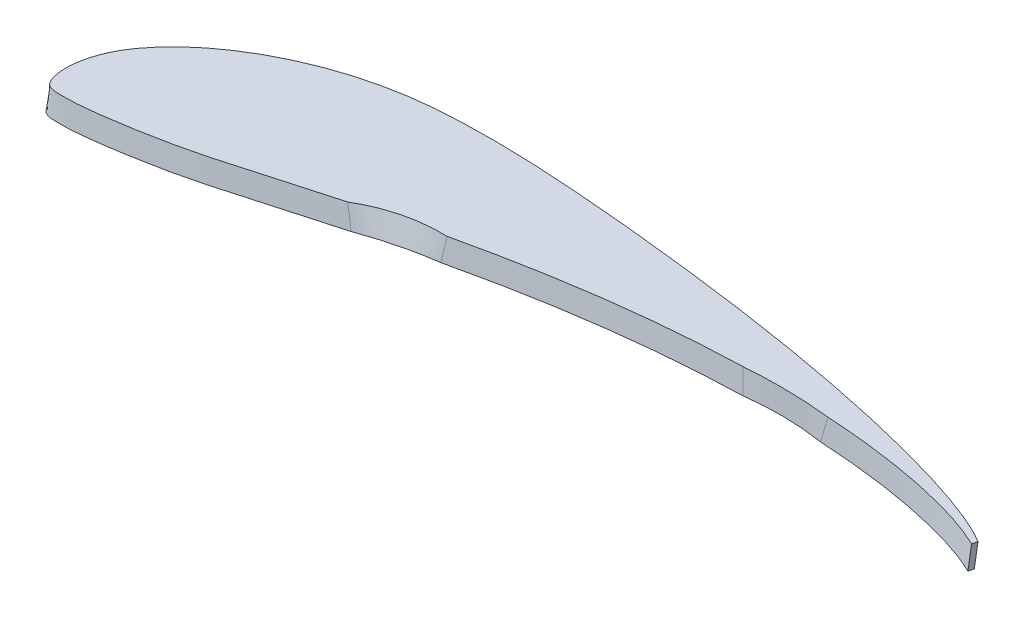
from build123d import *


with BuildPart() as part:
    # Szkic1 → Wyciągnięcie po profilach1 section 0
    with BuildSketch(Plane(origin=(0, 250.36091718, 48.665232477), x_dir=(1, 0, 0), z_dir=(0, -0.981627183, -0.190808995))):
        with BuildLine():
            Line((-230.718181465, 186.71807225), (-231.645319449, 188.691942525))
            add(Edge.make_bspline(
                [(-231.645319449, 188.691942525), (-233.174644141, 187.999953464), (-234.721783332, 187.364140241), (-237.841249221, 186.171939505), (-239.414020678, 185.616954481), (-244.164400083, 184.053112564), (-247.374501337, 183.146719317), (-253.851623397, 181.51342164), (-257.119855918, 180.780316602), (-263.657686797, 179.453922888), (-266.932791453, 178.860184209), (-276.773612098, 177.252991106), (-283.354734665, 176.412436258), (-296.548078516, 175.080330415), (-303.160298205, 174.588761507), (-309.785788347, 174.246119623)],
                knots=[0, 0, 0, 0, 0.0625, 0.0625, 0.125, 0.125, 0.25, 0.25, 0.375, 0.375, 0.5, 0.5, 0.75, 0.75, 1, 1, 1, 1], degree=3))
            add(Edge.make_bspline(
                [(-348.183016714, 173.781671183), (-328.964171571, 172.456994761), (-309.785788347, 174.246119623)],
                knots=[0, 0, 0, 1, 1, 1], degree=2))
            add(Edge.make_bspline(
                [(-348.183016714, 173.781671183), (-358.151666656, 174.022025786), (-368.096286676, 174.522537173), (-387.94418485, 175.971142244), (-397.847591779, 176.917841756), (-417.618208057, 179.203129122), (-427.484934044, 180.546950038), (-442.260684852, 182.826175434), (-447.183290441, 183.629033837), (-457.009652818, 185.314266402), (-461.914365461, 186.197158818), (-466.811292159, 187.117080937)],
                knots=[0, 0, 0, 0, 0.25, 0.25, 0.5, 0.5, 0.75, 0.75, 0.875, 0.875, 1, 1, 1, 1], degree=3))
            add(Edge.make_bspline(
                [(-503.67525068, 194.699844137), (-486.113087933, 186.628450015), (-466.811292159, 187.117080937)],
                knots=[0, 0, 0, 1, 1, 1], degree=2))
            add(Edge.make_bspline(
                [(-503.67525068, 194.699844137), (-514.886156137, 197.183158341), (-526.069069208, 199.799603445), (-542.843173548, 203.725532692), (-548.433789911, 205.045195718), (-556.847390253, 206.862217693), (-559.656198502, 207.441328721), (-565.285707455, 208.525652892), (-568.106893587, 209.027849652), (-573.758546812, 209.974572715), (-576.588548469, 210.421991156), (-582.255411466, 211.274203028), (-585.092466698, 211.677791635), (-590.775811551, 212.427587781), (-593.622461186, 212.771558242), (-597.902598645, 213.224362574), (-599.33093878, 213.36518339), (-602.190977957, 213.625953291), (-603.621807395, 213.74850469), (-605.769052097, 213.890532369), (-606.485034549, 213.930761383), (-607.917647629, 213.991533363), (-608.634307809, 214.011178807), (-610.068244724, 214.031744007), (-610.785502514, 214.03323918), (-612.220370634, 214.025522336), (-612.937904151, 214.018643253), (-614.373446848, 213.990438557), (-615.094405741, 213.959551393), (-616.154316733, 213.800587864), (-616.504425777, 213.729005846), (-617.19627763, 213.537146432), (-617.539907955, 213.417073554), (-618.025928813, 213.187044681), (-618.183588752, 213.101834107), (-618.487632655, 212.909275387), (-618.635214003, 212.800703818), (-618.905216661, 212.56311753), (-619.028373994, 212.433641543), (-619.248292015, 212.150880775), (-619.346463926, 211.996467784), (-619.602643649, 211.519652342), (-619.725174636, 211.184978082), (-619.922621807, 210.499055279), (-619.997357698, 210.146675653), (-620.122117308, 209.439404469), (-620.169952886, 209.083937157), (-620.236946265, 208.369390812), (-620.256057026, 208.009403538), (-620.272323599, 206.93673215), (-620.228983229, 206.228087719), (-620.060745622, 204.820536998), (-619.93589689, 204.121624917), (-619.624483911, 202.731169778), (-619.437495298, 202.038892606), (-618.800725774, 200.000887185), (-618.274140545, 198.683280498), (-617.06173932, 196.112125571), (-616.37402886, 194.854996442), (-614.892048313, 192.440246872), (-614.092796263, 191.278019838), (-612.383886198, 189.039120678), (-611.475247542, 187.961658639), (-610.045682759, 186.397079988), (-609.558049109, 185.884164636), (-608.562812036, 184.87380875), (-608.054261942, 184.375495234), (-606.510608451, 182.909046548), (-605.457949932, 181.968180201), (-602.246891056, 179.228432719), (-600.032107811, 177.517553058), (-595.480994707, 174.285501661), (-593.145169014, 172.763543035), (-588.374611336, 169.873997071), (-585.940036539, 168.506164399), (-580.983288597, 165.907221095), (-578.460054833, 164.67776586), (-574.613641656, 162.92966878), (-573.321179813, 162.362813896), (-570.72874085, 161.263307356), (-569.427344918, 160.729821284), (-565.508102562, 159.176672617), (-562.875139683, 158.204514072), (-557.57061981, 156.381480503), (-554.89911711, 155.530434856), (-549.519642901, 153.942948231), (-546.811580447, 153.206793044), (-542.719703975, 152.196153858), (-541.350718573, 151.875070349), (-538.602803254, 151.264154355), (-537.222650497, 150.973945298), (-533.07763064, 150.149751095), (-530.312072996, 149.661683583), (-524.776746306, 148.802487292), (-522.006930458, 148.432658084), (-516.462903089, 147.81505516), (-513.688733399, 147.566119904), (-505.360707441, 146.972502593), (-499.801157696, 146.785912361), (-488.675496216, 146.594939917), (-483.108917997, 146.60351064), (-471.96845567, 146.823516049), (-466.394878068, 147.026439938), (-455.243137073, 147.559622222), (-449.662553722, 147.891994248), (-438.516776064, 148.643989656), (-432.94937268, 149.06163809), (-421.823476404, 149.964591923), (-416.26507807, 150.450615294), (-405.155380964, 151.476568692), (-399.604088693, 152.016548071), (-382.963513349, 153.73748367), (-371.887469562, 155.018965175), (-355.303574737, 157.170273359), (-349.780935591, 157.927814607), (-338.747461606, 159.532526677), (-333.236280066, 160.377065009), (-322.22686618, 162.164464305), (-316.728864243, 163.109074761), (-305.747305667, 165.107978159), (-300.263728509, 166.162115302), (-292.052072184, 167.847415948), (-289.317157844, 168.426680304), (-283.852570751, 169.625008143), (-281.12178784, 170.244451213), (-272.949727013, 172.169989218), (-267.527009062, 173.540386835), (-259.449271288, 175.788890801), (-256.766293113, 176.571266618), (-251.42592644, 178.223638349), (-248.768221826, 179.092551866), (-244.808978612, 180.489445382), (-243.493864392, 180.970941908), (-240.874964635, 181.972724826), (-239.570510548, 182.493630845), (-236.985358252, 183.58161694), (-235.702414065, 184.146108379), (-233.174982125, 185.356932848), (-231.93081956, 186.003957932), (-230.718181465, 186.71807225)],
                knots=[0, 0, 0, 0, 0.0625, 0.0625, 0.09375, 0.09375, 0.109375, 0.109375, 0.125, 0.125, 0.140625, 0.140625, 0.15625, 0.15625, 0.171875, 0.171875, 0.1796875, 0.1796875, 0.1875, 0.1875, 0.19140625, 0.19140625, 0.1953125, 0.1953125, 0.19921875, 0.19921875, 0.203125, 0.203125, 0.20703125, 0.20703125, 0.208984375, 0.208984375, 0.2109375, 0.2109375, 0.211914062, 0.211914062, 0.212890625, 0.212890625, 0.213867187, 0.213867187, 0.21484375, 0.21484375, 0.216796875, 0.216796875, 0.21875, 0.21875, 0.220703125, 0.220703125, 0.22265625, 0.22265625, 0.2265625, 0.2265625, 0.23046875, 0.23046875, 0.234375, 0.234375, 0.2421875, 0.2421875, 0.25, 0.25, 0.2578125, 0.2578125, 0.265625, 0.265625, 0.26953125, 0.26953125, 0.2734375, 0.2734375, 0.28125, 0.28125, 0.296875, 0.296875, 0.3125, 0.3125, 0.328125, 0.328125, 0.34375, 0.34375, 0.3515625, 0.3515625, 0.359375, 0.359375, 0.375, 0.375, 0.390625, 0.390625, 0.40625, 0.40625, 0.4140625, 0.4140625, 0.421875, 0.421875, 0.4375, 0.4375, 0.453125, 0.453125, 0.46875, 0.46875, 0.5, 0.5, 0.53125, 0.53125, 0.5625, 0.5625, 0.59375, 0.59375, 0.625, 0.625, 0.65625, 0.65625, 0.6875, 0.6875, 0.75, 0.75, 0.78125, 0.78125, 0.8125, 0.8125, 0.84375, 0.84375, 0.875, 0.875, 0.890625, 0.890625, 0.90625, 0.90625, 0.9375, 0.9375, 0.953125, 0.953125, 0.96875, 0.96875, 0.9765625, 0.9765625, 0.984375, 0.984375, 0.9921875, 0.9921875, 1, 1, 1, 1], degree=3))
        make_face()
    # Szkic2 → Wyciągnięcie po profilach1 section 1
    with BuildSketch(Plane(origin=(0, 241.329947092, 46.90978972), x_dir=(1, 0, 0), z_dir=(0, 0.981627183, 0.190808995))):
        with BuildLine():
            Line((-231.646212924, -192.150787371), (-230.719075123, -190.177260074))
            add(Edge.make_bspline(
                [(-230.719075123, -190.177260074), (-231.948901198, -189.453147906), (-233.20887904, -188.799403111), (-235.755254104, -187.582025717), (-237.043499625, -187.016387422), (-240.930581019, -185.383355833), (-243.555608344, -184.390843227), (-248.847871126, -182.52648997), (-251.515431557, -181.655578415), (-256.880143927, -179.998356663), (-259.577649206, -179.213056657), (-264.995498516, -177.707752045), (-267.716935541, -176.987652686), (-273.173189749, -175.60008308), (-275.90549341, -174.933883516), (-284.112891469, -173.004549654), (-289.598440536, -171.810466147), (-300.590412603, -169.560166875), (-306.096893758, -168.504335203), (-317.126413334, -166.502028969), (-322.649511073, -165.555946181), (-339.241976719, -162.87074662), (-350.332670964, -161.272485615), (-372.563252551, -158.400873194), (-383.701752049, -157.11835537), (-400.440188062, -155.397257975), (-406.024765373, -154.857234239), (-417.202083272, -153.831103416), (-422.796533028, -153.345581305), (-433.986186707, -152.44597855), (-439.581401193, -152.030775931), (-450.77280575, -151.287445217), (-456.369020983, -150.961562741), (-467.56296205, -150.444624481), (-473.160663276, -150.251372161), (-484.358234817, -150.058466439), (-489.958194001, -150.066744834), (-501.160441068, -150.291146194), (-506.762696657, -150.504386826), (-515.169825975, -151.158585683), (-517.972805094, -151.430443194), (-523.580181633, -152.100746661), (-526.387775415, -152.499530907), (-534.74074073, -153.866708494), (-540.240829662, -155.003321589), (-548.374919876, -157.089374494), (-551.067687575, -157.845801363), (-556.418550136, -159.472534871), (-559.076397943, -160.343652941), (-564.354873991, -162.208133352), (-566.975486778, -163.201546453), (-572.177838401, -165.3160506), (-574.759951718, -166.435911696), (-579.879028517, -168.823924411), (-582.421458486, -170.096690144), (-587.399982445, -172.780552185), (-589.842302197, -174.192094015), (-597.006211419, -178.668507031), (-601.567430201, -181.97119253), (-606.86619118, -186.696807469), (-607.907306115, -187.674953253), (-609.906600664, -189.689607526), (-610.867466168, -190.728126276), (-612.692971166, -192.882556951), (-613.557169123, -193.998824), (-614.767234871, -195.74257906), (-615.156519044, -196.335147907), (-615.906188642, -197.543528445), (-616.267154497, -198.16035143), (-617.301224195, -200.040237034), (-617.918858094, -201.321366231), (-618.975723877, -203.952930941), (-619.415386547, -205.303199099), (-619.901035927, -207.396137179), (-620.033628179, -208.103829749), (-620.216014742, -209.518810025), (-620.291835155, -210.58421703), (-620.247970749, -211.657813386), (-620.189568984, -212.375539464), (-620.145782556, -212.734004312), (-620.029737618, -213.442239209), (-619.959696192, -213.793681415), (-619.821977141, -214.313575775), (-619.770256163, -214.485579644), (-619.649925655, -214.82582824), (-619.580724196, -214.995255164), (-619.421796717, -215.320531679), (-619.332121654, -215.476717239), (-619.125867399, -215.772087212), (-619.007079731, -215.912200799), (-618.614803353, -216.291802882), (-618.312542654, -216.492025046), (-617.663313635, -216.822106069), (-617.325971244, -216.94742188), (-616.636386212, -217.151548677), (-616.282981523, -217.229675381), (-615.209916887, -217.404292633), (-614.486665384, -217.439932408), (-613.401279794, -217.46385096), (-613.039751167, -217.468018286), (-612.316665207, -217.476762746), (-611.955184164, -217.480250774), (-610.148242152, -217.491078281), (-608.704263711, -217.477253344), (-605.822771219, -217.357318588), (-604.384829895, -217.257308462), (-601.511437363, -217.0217396), (-600.075759723, -216.889413383), (-597.205655435, -216.606901928), (-595.771336145, -216.455184064), (-591.470516624, -215.969503622), (-588.605394881, -215.604293633), (-582.887207402, -214.820011263), (-580.032906206, -214.401642781), (-574.332562265, -213.519711277), (-571.486095774, -213.058467216), (-565.80456902, -212.073558268), (-562.970172606, -211.546260463), (-557.315094211, -210.416612326), (-554.493828971, -209.817453892), (-548.859970661, -208.571678404), (-546.047324243, -207.925353296), (-540.424831829, -206.617377706), (-537.614741724, -205.957579388), (-523.561857343, -202.670887625), (-512.317333578, -200.052078006), (-501.042625967, -197.576867128)],
                knots=[0, 0, 0, 0, 0.0078125, 0.0078125, 0.015625, 0.015625, 0.03125, 0.03125, 0.046875, 0.046875, 0.0625, 0.0625, 0.078125, 0.078125, 0.09375, 0.09375, 0.125, 0.125, 0.15625, 0.15625, 0.1875, 0.1875, 0.25, 0.25, 0.3125, 0.3125, 0.34375, 0.34375, 0.375, 0.375, 0.40625, 0.40625, 0.4375, 0.4375, 0.46875, 0.46875, 0.5, 0.5, 0.53125, 0.53125, 0.546875, 0.546875, 0.5625, 0.5625, 0.59375, 0.59375, 0.609375, 0.609375, 0.625, 0.625, 0.640625, 0.640625, 0.65625, 0.65625, 0.671875, 0.671875, 0.6875, 0.6875, 0.71875, 0.71875, 0.7265625, 0.7265625, 0.734375, 0.734375, 0.7421875, 0.7421875, 0.74609375, 0.74609375, 0.75, 0.75, 0.7578125, 0.7578125, 0.765625, 0.765625, 0.76953125, 0.76953125, 0.7734375, 0.775390625, 0.775390625, 0.77734375, 0.77734375, 0.779296875, 0.779296875, 0.780273437, 0.780273437, 0.78125, 0.78125, 0.782226562, 0.782226562, 0.783203125, 0.783203125, 0.78515625, 0.78515625, 0.787109375, 0.787109375, 0.7890625, 0.7890625, 0.79296875, 0.79296875, 0.794921875, 0.794921875, 0.796875, 0.796875, 0.8046875, 0.8046875, 0.8125, 0.8125, 0.8203125, 0.8203125, 0.828125, 0.828125, 0.84375, 0.84375, 0.859375, 0.859375, 0.875, 0.875, 0.890625, 0.890625, 0.90625, 0.90625, 0.921875, 0.921875, 0.9375, 0.9375, 1, 1, 1, 1], degree=3))
            add(Edge.make_bspline(
                [(-501.042625967, -197.576867128), (-484.70639457, -192.735609928), (-467.788308948, -190.760045533)],
                knots=[0, 0, 0, 1, 1, 1], degree=2))
            add(Edge.make_bspline(
                [(-467.788308948, -190.760045533), (-462.786676869, -189.815443547), (-457.776990743, -188.909158453), (-447.739980306, -187.180501396), (-442.71289445, -186.357785178), (-427.622254664, -184.024069495), (-417.54302444, -182.650776587), (-397.341308596, -180.324047944), (-387.219395985, -179.365050328), (-372.000474202, -178.276499945), (-366.921451485, -177.972362208), (-356.750298544, -177.491314356), (-351.654106922, -177.314334211), (-346.563485915, -177.206095001)],
                knots=[0, 0, 0, 0, 0.125, 0.125, 0.25, 0.25, 0.5, 0.5, 0.75, 0.75, 0.875, 0.875, 1, 1, 1, 1], degree=3))
            add(Edge.make_bspline(
                [(-346.563485915, -177.206095001), (-329.06213864, -175.248845373), (-311.621831541, -177.616174998)],
                knots=[0, 0, 0, 1, 1, 1], degree=2))
            add(Edge.make_bspline(
                [(-311.621831541, -177.616174998), (-304.850539253, -177.938142667), (-298.091025125, -178.413813258), (-284.599556619, -179.724804329), (-277.867583166, -180.559875897), (-267.797000058, -182.169749214), (-264.444739267, -182.766406042), (-259.424595361, -183.76901685), (-257.752603343, -184.121350362), (-254.41170897, -184.866336955), (-252.743343717, -185.258479423), (-247.763643812, -186.499890794), (-244.473002096, -187.419099547), (-239.604690543, -189.01043981), (-237.993069173, -189.57591185), (-234.797111805, -190.792573508), (-233.212305749, -191.44228643), (-231.646212924, -192.150787371)],
                knots=[0, 0, 0, 0, 0.25, 0.25, 0.5, 0.5, 0.625, 0.625, 0.6875, 0.6875, 0.75, 0.75, 0.875, 0.875, 0.9375, 0.9375, 1, 1, 1, 1], degree=3))
        make_face()
    loft()


solid = part.part
